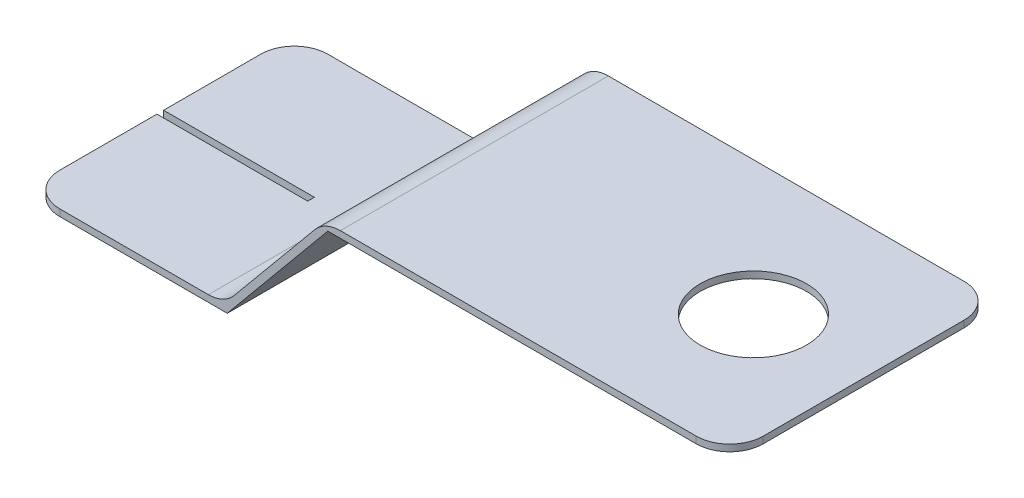
from build123d import *

# Parameters (mm, degrees)
BOSS_EXTRUDE1_DEPTH = 4
SKETCH2_R           = 1.5875
CUT_EXTRUDE1_DEPTH  = 10
FILLET1_R           = 1
SKETCH3_W           = 4.5
SKETCH3_H           = 0.2
CUT_EXTRUDE2_DEPTH  = 10
FILLET2_R           = 1


with BuildPart() as part:
    # Sketch1 → Boss-Extrude1 (new body, symmetric)
    with BuildSketch(Plane.XY):
        Polygon((0, 0), (6, 0), (9, 3.625), (21, 3.625), (21, 3.825), (8.905909928, 3.825), (5.905909928, 0.2), (0, 0.2), align=None)
    extrude(amount=BOSS_EXTRUDE1_DEPTH, both=True)

    # Sketch2 → Cut-Extrude1 (cut)
    with BuildSketch(Plane(origin=(0, 3.825, 0), x_dir=(1, 0, 0), z_dir=(0, 1, 0))):
        with Locations((17.705909928, 0)):
            Circle(SKETCH2_R)
    extrude(amount=-CUT_EXTRUDE1_DEPTH, mode=Mode.SUBTRACT)

    # Fillet1
    fillet1_edges = [part.edges().sort_by_distance(p)[0] for p in [
        (0, 0.1, -4),
        (21, 3.725, 4),
        (0, 0.1, 4),
        (21, 3.725, -4),
    ]]
    fillet(fillet1_edges, radius=FILLET1_R)

    # Sketch3 → Cut-Extrude2 (cut)
    with BuildSketch(Plane(origin=(0, 0.2, 0), x_dir=(1, 0, 0), z_dir=(0, 1, 0))):
        with Locations((2.25, 0)):
            Rectangle(SKETCH3_W, SKETCH3_H)
    extrude(amount=-CUT_EXTRUDE2_DEPTH, mode=Mode.SUBTRACT)

    # Fillet2
    fillet2_edges = [part.edges().sort_by_distance(p)[0] for p in [
        (5.905909928, 0.2, 0),
        (8.905909928, 3.825, 0),
    ]]
    fillet(fillet2_edges, radius=FILLET2_R)


solid = part.part
